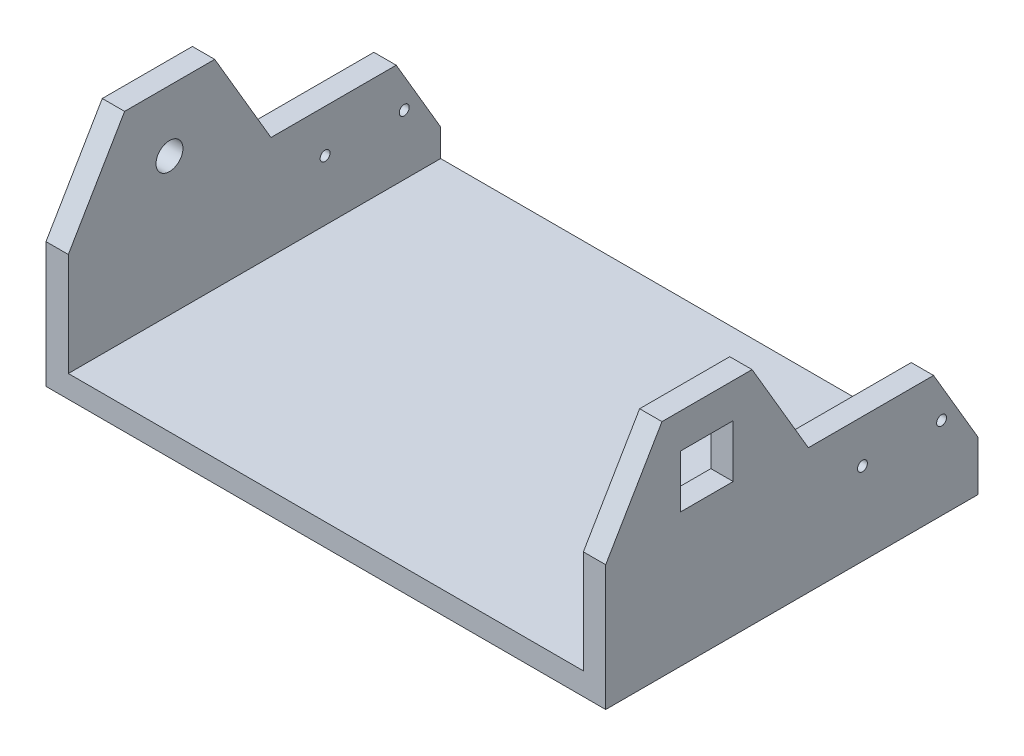
from build123d import *

# Parameters (mm, degrees)
SKETCH1_W           = 451
SKETCH1_H           = 300
BOSS_EXTRUDE6_DEPTH = 18
SKETCH4_R           = 4
SKETCH4_W           = 42.5
SKETCH4_H           = 42.5
BOSS_EXTRUDE7_DEPTH = 18
SKETCH5_R           = 10.85
SKETCH5_R_2         = 4
BOSS_EXTRUDE8_DEPTH = 18


with BuildPart() as part:
    # Sketch1 → Boss-Extrude6 (new body)
    with BuildSketch(Plane(origin=(0, 0, 0), x_dir=(1, 0, 0), z_dir=(0, 1, 0))):
        with Locations((225.5, 150)):
            Rectangle(SKETCH1_W, SKETCH1_H)
    extrude(amount=BOSS_EXTRUDE6_DEPTH)

    # Sketch4 → Boss-Extrude7 (add)
    with BuildSketch(Plane(origin=(451, 0, 0), x_dir=(0, 0, -1), z_dir=(1, 0, 0))):
        Polygon((0, 0), (0, 101.059625538), (45.34233012, 178.261418028), (117.954980558, 178.261418028), (163.295274024, 101.059625538), (264.202994821, 101.059625538), (300, 40.107374144), (300, 0), align=None)
        with Locations((206.89, 66.5)):
            Circle(SKETCH4_R, mode=Mode.SUBTRACT)
        with Locations((270.64, 66.5)):
            Circle(SKETCH4_R, mode=Mode.SUBTRACT)
        with Locations((81.5, 129)):
            Rectangle(SKETCH4_W, SKETCH4_H, mode=Mode.SUBTRACT)
    extrude(amount=-BOSS_EXTRUDE7_DEPTH)

    # Sketch5 → Boss-Extrude8 (add)
    with BuildSketch(Plane.ZY):
        Polygon((-300, 0), (-300, 40.107374144), (-264.202994821, 101.059625538), (-163.295274024, 101.059625538), (-117.954980558, 178.261418028), (-45.34233012, 178.261418028), (0, 101.059625538), (0, 0), align=None)
        with Locations((-81.5, 129)):
            Circle(SKETCH5_R, mode=Mode.SUBTRACT)
        with Locations((-270.64, 66.5)):
            Circle(SKETCH5_R_2, mode=Mode.SUBTRACT)
        with Locations((-206.89, 66.5)):
            Circle(SKETCH5_R_2, mode=Mode.SUBTRACT)
    extrude(amount=-BOSS_EXTRUDE8_DEPTH)


solid = part.part
